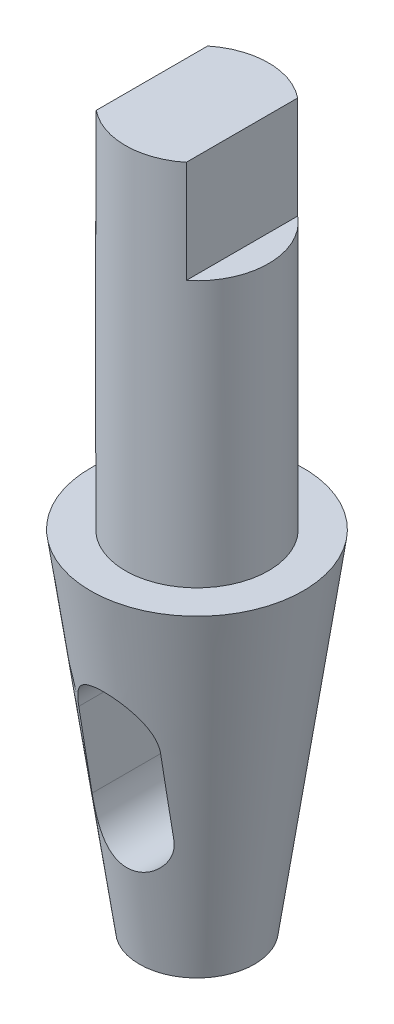
from build123d import *

# Parameters (mm, degrees)
CUT_EXTRUDE_1_DEPTH = 25
CUT_EXTRUDE_2_DEPTH = 25


with BuildPart() as part:
    # Эскиз1 → Повернуть1 (revolve)
    with BuildSketch(Plane.XY):
        Polygon((0, 0), (17.5, 0), (17.5, -90), (26, -90), (14.05402905, -175), (0, -175), align=None)
    revolve(axis=Axis((0, 0, 0), (0, -1, 0)))

    # Эскиз2 → Вырез-Вытянуть1 (cut, symmetric)
    with BuildSketch(Plane.XY):
        with BuildLine():
            Line((10, -123), (10, -143))
            ThreePointArc((10, -143), (0, -153), (-10, -143))
            Line((-10, -143), (-10, -123))
            ThreePointArc((-10, -123), (0, -113), (10, -123))
        make_face()
    extrude(amount=CUT_EXTRUDE_1_DEPTH, both=True, mode=Mode.SUBTRACT)

    # Эскиз3 → Вырез-Вытянуть2 (cut)
    with BuildSketch(Plane(origin=(0, 0, 0), x_dir=(1, 0, 0), z_dir=(0, 1, 0))):
        with BuildLine():
            Line((-11, -13.610657589), (-11, 13.610657589))
            ThreePointArc((-11, 13.610657589), (-17.5, 0), (-11, -13.610657589))
        make_face()
        with BuildLine():
            ThreePointArc((17.5, 0), (15.791611697, 7.541551564), (11, 13.610657589))
            Line((11, 13.610657589), (11, -13.610657589))
            ThreePointArc((11, -13.610657589), (15.791611697, -7.541551564), (17.5, 0))
        make_face()
    extrude(amount=-CUT_EXTRUDE_2_DEPTH, mode=Mode.SUBTRACT)


solid = part.part
